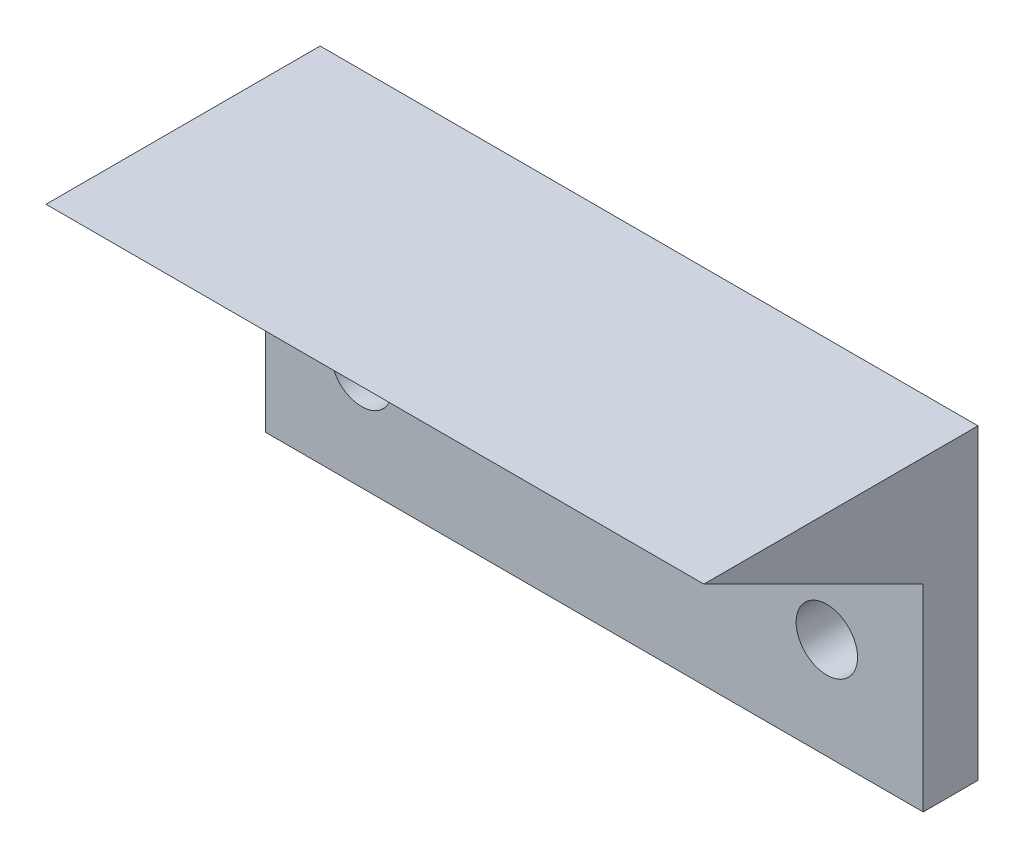
from build123d import *

# Parameters (mm, degrees)
SKETCH1_W           = 38.1
SKETCH1_H           = 17.78
SKETCH1_R           = 1.778
BOSS_EXTRUDE2_DEPTH = 3.175
BOSS_EXTRUDE3_DEPTH = 38.1


with BuildPart() as part:
    # Sketch1 → Boss-Extrude2 (new body)
    with BuildSketch(Plane.XY):
        with Locations((19.05, -8.89)):
            Rectangle(SKETCH1_W, SKETCH1_H)
        with Locations((5.579618, -11.929615714)):
            Circle(SKETCH1_R, mode=Mode.SUBTRACT)
        with Locations((32.520382, -11.929615714)):
            Circle(SKETCH1_R, mode=Mode.SUBTRACT)
    extrude(amount=BOSS_EXTRUDE2_DEPTH)

    # Sketch4 → Boss-Extrude3 (add)
    with BuildSketch(Plane(origin=(38.1, 0, 0), x_dir=(0, 0, -1), z_dir=(1, 0, 0))):
        Polygon((-3.175, -6.35), (-15.875, 0), (-3.175, 0), align=None)
    extrude(amount=-BOSS_EXTRUDE3_DEPTH)


solid = part.part
